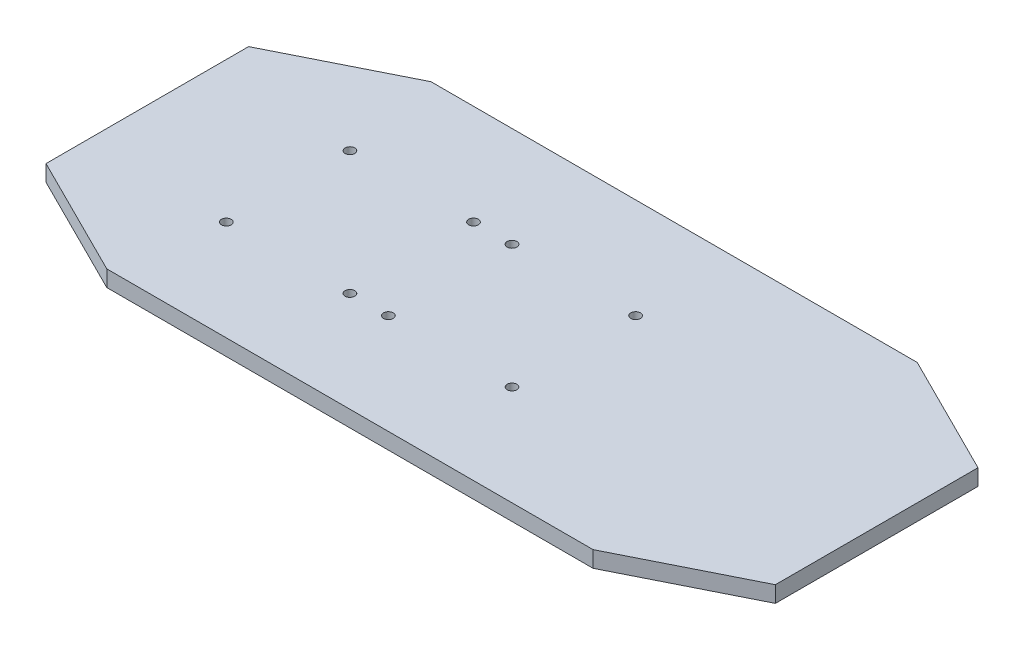
from build123d import *

# Parameters (mm, degrees)
ESQUISSE1_W             = 180
ESQUISSE1_H             = 80
BOSS_EXTRU_1_DEPTH      = 4
ENL_V_MAT_EXTRU_1_DEPTH = 4
D_GAGEMENT_M22_D        = 2.4
D_GAGEMENT_M23_D        = 2.4


with BuildPart() as part:
    # Esquisse1 → Boss.-Extru.1 (new body)
    with BuildSketch(Plane(origin=(0, 0, 0), x_dir=(1, 0, 0), z_dir=(0, 1, 0))):
        with Locations((90, 40)):
            Rectangle(ESQUISSE1_W, ESQUISSE1_H)
    extrude(amount=BOSS_EXTRU_1_DEPTH)

    # Esquisse2 → Enlèv. mat.-Extru.1 (cut)
    with BuildSketch(Plane(origin=(0, 4, 0), x_dir=(1, 0, 0), z_dir=(0, 1, 0))):
        Polygon((0, 15), (30, 0), (0, 0), align=None)
        Polygon((30, 80), (0, 65), (0, 80), align=None)
        Polygon((150, 80), (180, 80), (180, 65), align=None)
        Polygon((180, 15), (150, 0), (180, 0), align=None)
    extrude(amount=-ENL_V_MAT_EXTRU_1_DEPTH, mode=Mode.SUBTRACT)

    # Dégagement M22 (through all)
    with Locations(Plane(origin=(0, 4, 0), x_dir=(1, 0, 0), z_dir=(0, 1, 0))):
        with Locations((74.75, 55.25), (105.25, 55.25), (105.25, 24.75), (74.75, 24.75)):
            Hole(D_GAGEMENT_M22_D / 2)

    # Dégagement M23 (through all)
    with Locations(Plane(origin=(0, 4, 0), x_dir=(1, 0, 0), z_dir=(0, 1, 0))):
        with Locations((34.75, 24.75), (65.25, 24.75), (65.25, 55.25), (34.75, 55.25)):
            Hole(D_GAGEMENT_M23_D / 2)


solid = part.part
